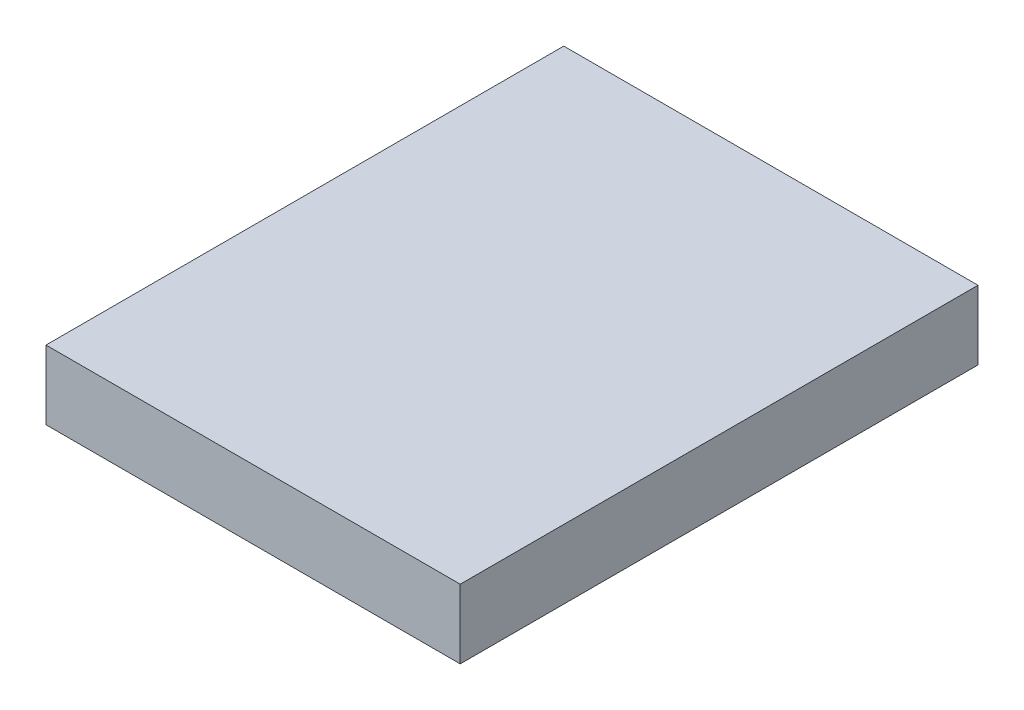
from build123d import *

# Parameters (mm, degrees)
SKETCH1_W           = 229
SKETCH1_H           = 12.7
BOSS_EXTRUDE1_DEPTH = 1
SKETCH4_W           = 6
SKETCH4_H           = 5.2
CUT_EXTRUDE3_DEPTH  = 2


with BuildPart() as part:
    # Sketch1 → Boss-Extrude1 (new body)
    with BuildSketch(Plane(origin=(0, 0, 0), x_dir=(1, 0, 0), z_dir=(0, 1, 0))):
        with Locations((114.5, -6.35)):
            Rectangle(SKETCH1_W, SKETCH1_H)
    extrude(amount=-BOSS_EXTRUDE1_DEPTH)

    # Sketch4 → Cut-Extrude3 (cut, through all)
    with BuildSketch(Plane(origin=(0, 0, 0), x_dir=(1, 0, 0), z_dir=(0, 1, 0))):
        Polygon((6, -12.7), (229, -12.7), (229, 0), (6, 0), (6, -7.5), align=None)
        with Locations((3, -10.1)):
            Rectangle(SKETCH4_W, SKETCH4_H)
    extrude(amount=-CUT_EXTRUDE3_DEPTH, mode=Mode.SUBTRACT)


solid = part.part
